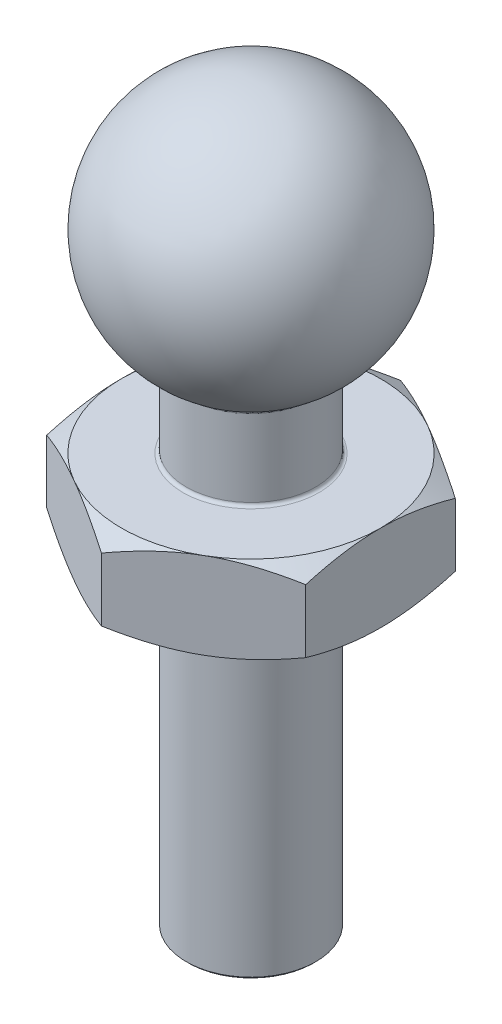
from build123d import *

# Parameters (mm, degrees)
CHAMFER1_SIZE       = 0.05
SKETCH4_R           = 1.5
BOSS_EXTRUDE2_DEPTH = 2
SKETCH5_OUTSIDE_W   = 18.79
SKETCH5_OUTSIDE_H   = 19.718
SKETCH5_OUTSIDE_R   = 3
CUT_EXTRUDE1_DEPTH  = 2
CUT_EXTRUDE1_TAPER  = 60
SKETCH6_OUTSIDE_W   = 18.79
SKETCH6_OUTSIDE_H   = 19.718
SKETCH6_OUTSIDE_R   = 3
CUT_EXTRUDE2_DEPTH  = 2
CUT_EXTRUDE2_TAPER  = 60
FILLET1_R           = 0.075


with BuildPart() as part:
    # Sketch1 → Revolve2 (revolve)
    with BuildSketch(Plane.XY):
        with BuildLine():
            Line((0, 0), (0, 11))
            Line((0, 11), (0, 17))
            ThreePointArc((0, 17), (2.897777479, 14.776457135), (1.5, 11.401923789))
            Line((1.5, 11.401923789), (1.5, 0))
            Line((1.5, 0), (0, 0))
        make_face()
    revolve(axis=Axis((0, 0, 0), (0, 1, 0)))

    # Chamfer1
    chamfer1_edges = [part.edges().sort_by_distance(p)[0] for p in [
        (-1.5, 0, 0),
    ]]
    chamfer(chamfer1_edges, length=CHAMFER1_SIZE)

    # Sketch4 → Boss-Extrude2 (add)
    with BuildSketch(Plane(origin=(0, 7.5, 0), x_dir=(1, 0, 0), z_dir=(0, 1, 0))):
        Polygon((0, -3.464101615), (3, -1.732050808), (3, 1.732050808), (0, 3.464101615), (-3, 1.732050808), (-3, -1.732050808), align=None)
        Circle(SKETCH4_R, mode=Mode.SUBTRACT)
    extrude(amount=BOSS_EXTRUDE2_DEPTH)

    # Sketch5 outside → Cut-Extrude1 (cut)
    with BuildSketch(Plane.XZ.offset(-7.5)):
        Rectangle(SKETCH5_OUTSIDE_W, SKETCH5_OUTSIDE_H)
        Circle(SKETCH5_OUTSIDE_R, mode=Mode.SUBTRACT)
    extrude(amount=-CUT_EXTRUDE1_DEPTH, taper=CUT_EXTRUDE1_TAPER, mode=Mode.SUBTRACT)

    # Sketch6 outside → Cut-Extrude2 (cut)
    with BuildSketch(Plane(origin=(0, 9.5, 0), x_dir=(1, 0, 0), z_dir=(0, 1, 0))):
        Rectangle(SKETCH6_OUTSIDE_W, SKETCH6_OUTSIDE_H)
        Circle(SKETCH6_OUTSIDE_R, mode=Mode.SUBTRACT)
    extrude(amount=-CUT_EXTRUDE2_DEPTH, taper=CUT_EXTRUDE2_TAPER, mode=Mode.SUBTRACT)

    # Fillet1
    fillet1_edges = [part.edges().sort_by_distance(p)[0] for p in [
        (-1.5, 9.5, 0),
        (-1.5, 11.401923789, 0),
    ]]
    fillet(fillet1_edges, radius=FILLET1_R)


solid = part.part
